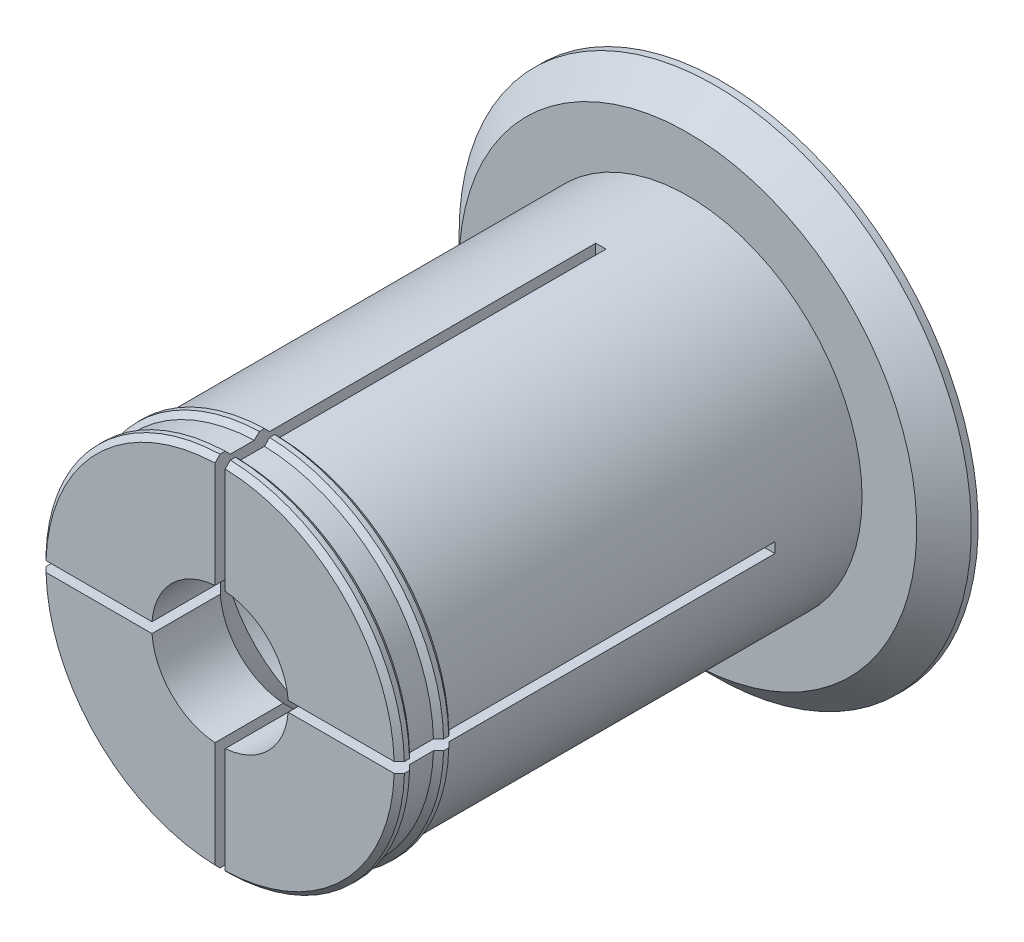
from build123d import *

# Parameters (mm, degrees)
AXLE_BASE_SKETCH_R        = 25.5
AXLE_DEPTH                = 68.5
GUARD_BASE_R              = 37.5
GUARD_DEPTH               = 5
INNER_AXLE_HOLE_BASE_R    = 10
INNER_AXLE_HOLE_DEPTH     = 74.5
BEND_START                = -55.75
BEND_ROOM_BASE_W          = 1.5
BEND_ROOM_BASE_H          = 75
BEND_ROOM_1_DEPTH         = 55.750001
BEND_ROOM_2_COUNT         = 2
BEND_ROOM_2_ANGLE         = 90
EASY_REMOVAL_CHAMFER_SIZE = 4


with BuildPart() as part:
    # Axle base sketch → Axle (new body)
    with BuildSketch(Plane.XY):
        Circle(AXLE_BASE_SKETCH_R)
    extrude(amount=AXLE_DEPTH)

    # Guard base → Guard (add)
    with BuildSketch(Plane(origin=(0, 0, 0), x_dir=(-1, 0, 0), z_dir=(0, 0, -1))):
        Circle(GUARD_BASE_R)
    extrude(amount=GUARD_DEPTH)

    # Inner axle hole base → Inner axle hole (cut, through all)
    with BuildSketch(Plane.XY.offset(68.5)):
        Circle(INNER_AXLE_HOLE_BASE_R)
    extrude(amount=-INNER_AXLE_HOLE_DEPTH, mode=Mode.SUBTRACT)

    # Mate ring base → Mate rings (revolve)
    with BuildSketch(Plane(origin=(0, 0, 0), x_dir=(1, 0, 0), z_dir=(0, 1, 0))):
        Polygon((25.5, -68.5), (26.25, -67.75), (26.25, -67), (25.5, -66.25), align=None)
        Polygon((25.5, -62.75), (26.25, -62), (26.25, -61.25), (25.5, -60.5), align=None)
    revolve(axis=Axis((0, 0, 0), (0, 0, -1)))

    # Inner mass remove base → Inner mass remove (revolve, cut)
    with BuildSketch(Plane(origin=(0, 0, 0), x_dir=(0, 0, -1), z_dir=(1, 0, 0))):
        Polygon((-68.5, 0), (-50.75, -17.75), (-12.75, -17.75), (5, 0), align=None)
    revolve(axis=Axis((0, 0, 0), (0, 0, -1)), mode=Mode.SUBTRACT)

    # Bend room base → Bend room 1 (cut)
    with BuildSketch(Plane.XY.offset(68.5).offset(BEND_START)):
        Rectangle(BEND_ROOM_BASE_W, BEND_ROOM_BASE_H)
    bend_room_1 = extrude(amount=BEND_ROOM_1_DEPTH, mode=Mode.SUBTRACT)

    # Bend room 2: Bend room 1 ×2 about axis
    bend_room_2_axis = Axis((0, 0, 0), (0, 0, -1))
    for i in range(1, BEND_ROOM_2_COUNT):
        add(bend_room_1.rotate(bend_room_2_axis, i * BEND_ROOM_2_ANGLE / (BEND_ROOM_2_COUNT - 1)), mode=Mode.SUBTRACT)

    # Easy removal chamfer
    easy_removal_chamfer_edges = [part.edges().sort_by_distance(p)[0] for p in [
        (37.5, 0, 0),
    ]]
    chamfer(easy_removal_chamfer_edges, length=EASY_REMOVAL_CHAMFER_SIZE)


solid = part.part
